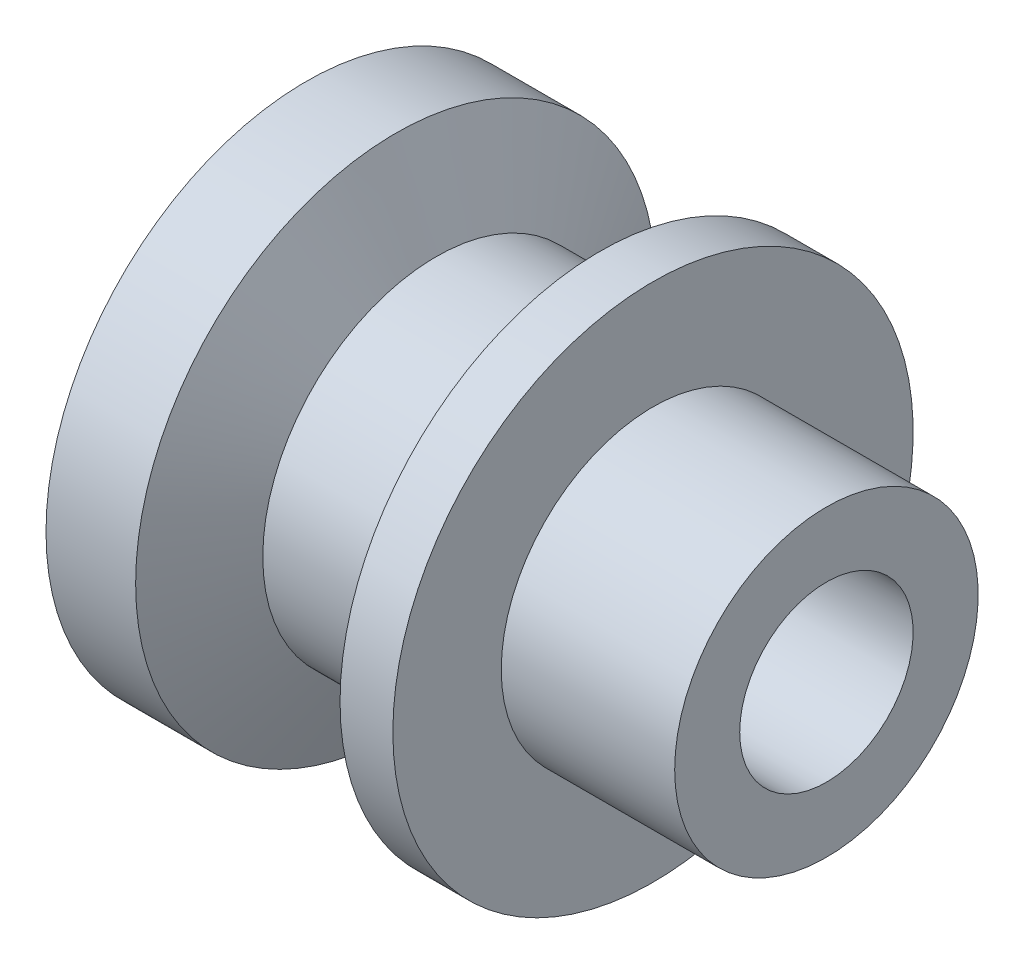
from build123d import *


with BuildPart() as part:
    # Sketch1 → Revolve1 (revolve)
    with BuildSketch(Plane.XY):
        Polygon((-52.152139616, 60), (-52.152139616, 20), (67.847860384, 20), (67.847860384, 35), (27.847860384, 35), (27.847860384, 60), (15.665876525, 60), (6.339723362, 40), (-22.152139616, 40), (-31.478292779, 60), align=None)
    revolve(axis=Axis((-49.678120063, 0, 0), (1, 0, 0)))


solid = part.part
